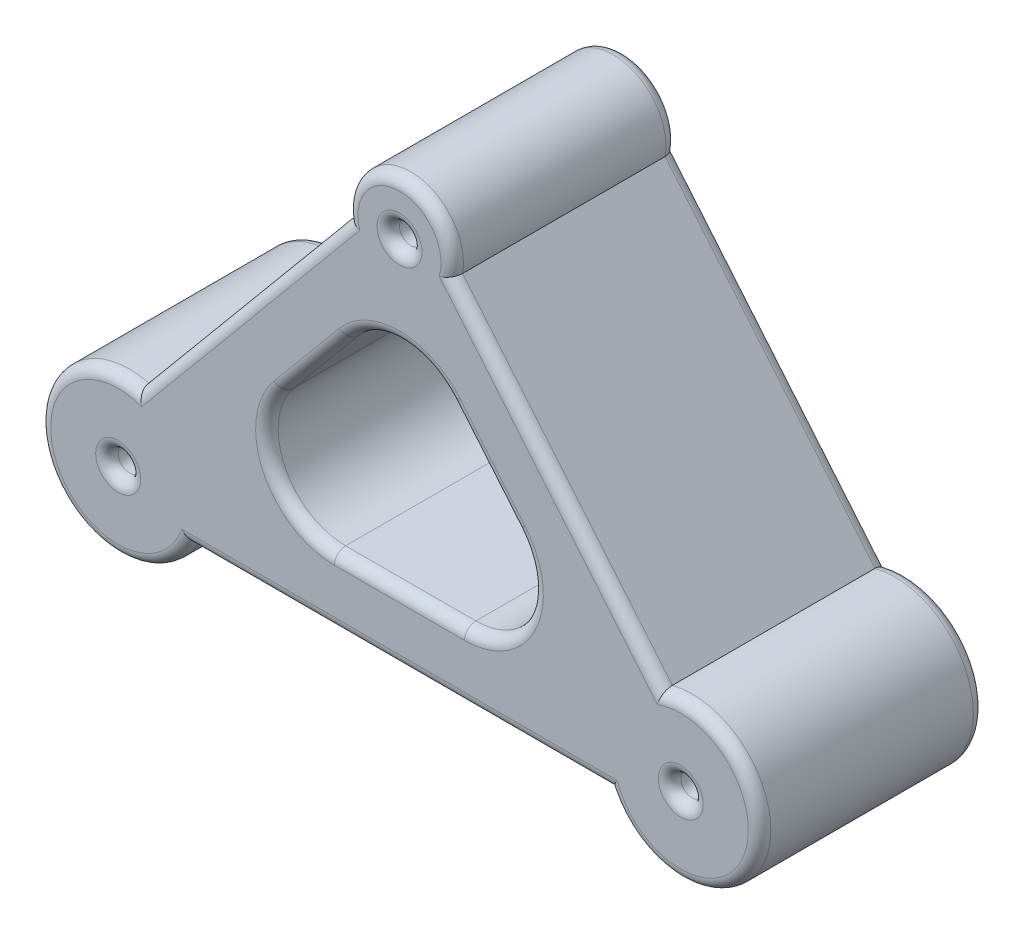
from build123d import *

# Parameters (mm, degrees)
ESQUISSE1_R        = 0.5
BOSS_EXTRU_1_DEPTH = 5
CONG_2_R           = 0.5


with BuildPart() as part:
    # Esquisse1 → Boss.-Extru.1 (new body, symmetric)
    with BuildSketch(Plane.XY):
        with BuildLine():
            Line((-11.627891094, 3.38960559), (-2.304663839, 14.577478296))
            ThreePointArc((-2.304663839, 14.577478296), (0, 17.343074903), (2.304663839, 14.577478296))
            Line((2.304663839, 14.577478296), (11.627891094, 3.38960559))
            ThreePointArc((11.627891094, 3.38960559), (15.669562974, -1.484543887), (9.33772234, -1.5))
            Line((9.33772234, -1.5), (-9.33772234, -1.5))
            ThreePointArc((-9.33772234, -1.5), (-15.669562974, -1.484543887), (-11.627891094, 3.38960559))
        make_face()
        with Locations((-12.5, 0)):
            Circle(ESQUISSE1_R, mode=Mode.SUBTRACT)
        with Locations((0, 15)):
            Circle(ESQUISSE1_R, mode=Mode.SUBTRACT)
        with Locations((12.5, 0)):
            Circle(ESQUISSE1_R, mode=Mode.SUBTRACT)
        with BuildLine():
            Line((-5.196976582, 6.420553199), (-2.304663839, 9.891328491))
            ThreePointArc((-2.304663839, 9.891328491), (0, 10.970775292), (2.304663839, 9.891328491))
            Line((2.304663839, 9.891328491), (5.196976582, 6.420553199))
            ThreePointArc((5.196976582, 6.420553199), (5.609081007, 3.227533811), (2.892312743, 1.5))
            Line((2.892312743, 1.5), (-2.892312743, 1.5))
            ThreePointArc((-2.892312743, 1.5), (-5.609081007, 3.227533811), (-5.196976582, 6.420553199))
        make_face(mode=Mode.SUBTRACT)
    extrude(amount=BOSS_EXTRU_1_DEPTH, both=True)

    # Congé2
    cong_2_edges = [part.edges().sort_by_distance(p)[0] for p in [
        (0, 17.343074903, 5),
        (-6.966277466, 8.983541943, 5),
        (-13, 0, -5),
        (-13, 0, 5),
        (-15.669562974, -1.484543887, 5),
        (0, -1.5, 5),
        (5.609081007, 3.227533811, -5),
        (3.75082021, 8.155940845, -5),
        (0, 10.970775292, -5),
        (-3.75082021, 8.155940845, -5),
        (-5.609081007, 3.227533811, -5),
        (0, 1.5, -5),
        (5.609081007, 3.227533811, 5),
        (3.75082021, 8.155940845, 5),
        (0, 10.970775292, 5),
        (-3.75082021, 8.155940845, 5),
        (-5.609081007, 3.227533811, 5),
        (0, 1.5, 5),
        (-0.5, 15, -5),
        (-0.5, 15, 5),
        (12, 0, -5),
        (12, 0, 5),
        (15.669562974, -1.484543887, 5),
        (0, -1.5, -5),
        (-15.669562974, -1.484543887, -5),
        (-6.966277466, 8.983541943, -5),
        (0, 17.343074903, -5),
        (6.966277466, 8.983541943, -5),
        (15.669562974, -1.484543887, -5),
        (6.966277466, 8.983541943, 5),
    ]]
    fillet(cong_2_edges, radius=CONG_2_R)


solid = part.part
